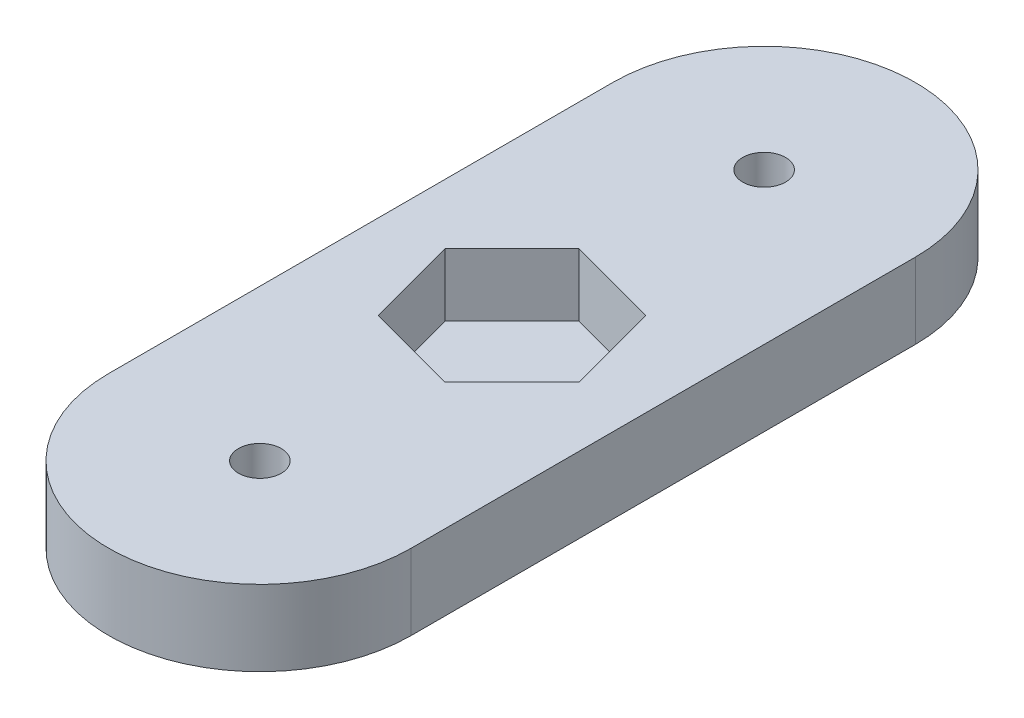
from build123d import *

# Parameters (mm, degrees)
SKETCH1_R           = 1.7
BOSS_EXTRUDE1_DEPTH = 6
CUT_EXTRUDE1_DEPTH  = 5


with BuildPart() as part:
    # Sketch1 → Boss-Extrude1 (new body)
    with BuildSketch(Plane(origin=(0, 0, 0), x_dir=(1, 0, 0), z_dir=(0, 1, 0))):
        with BuildLine():
            Line((-12, 0), (-12, 40))
            ThreePointArc((-12, 40), (0, 52), (12, 40))
            Line((12, 40), (12, 0))
            ThreePointArc((12, 0), (0, -12), (-12, 0))
        make_face()
        with Locations((0, 40)):
            Circle(SKETCH1_R, mode=Mode.SUBTRACT)
        Circle(SKETCH1_R, mode=Mode.SUBTRACT)
    extrude(amount=BOSS_EXTRUDE1_DEPTH)

    # Sketch2 → Cut-Extrude1 (cut)
    with BuildSketch(Plane(origin=(0, 6, 0), x_dir=(1, 0, 0), z_dir=(0, 1, 0))):
        Polygon((1.94258019, 12.750192034), (7.249807966, 18.05741981), (5.307227776, 25.307227776), (-1.94258019, 27.249807966), (-7.249807966, 21.94258019), (-5.307227776, 14.692772224), align=None)
    extrude(amount=-CUT_EXTRUDE1_DEPTH, mode=Mode.SUBTRACT)


solid = part.part
